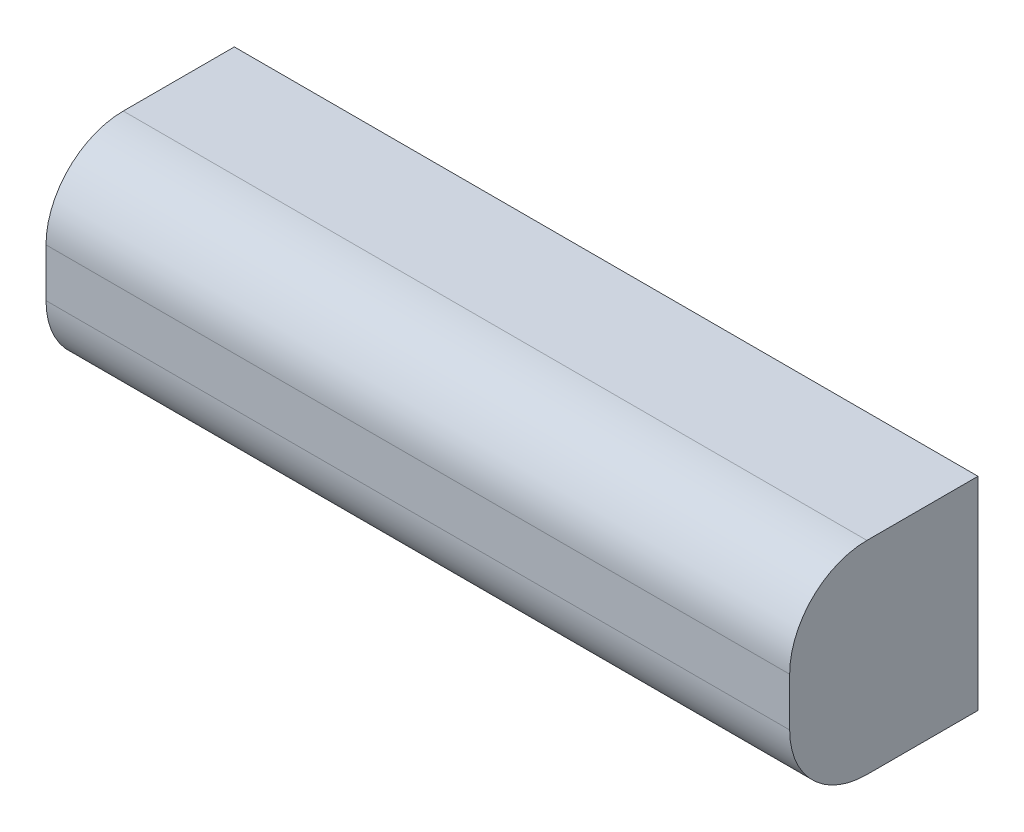
from build123d import *

# Parameters (mm, degrees)
SKICA1_W                = 77
SKICA1_H                = 21
P_IDAT_VYSUNUT_M1_DEPTH = 19.5
ZAOBLIT1_R              = 8


with BuildPart() as part:
    # Skica1 → Přidat vysunutím1 (new body)
    with BuildSketch(Plane.XY):
        Rectangle(SKICA1_W, SKICA1_H)
    extrude(amount=P_IDAT_VYSUNUT_M1_DEPTH)

    # Zaoblit1
    zaoblit1_edges = [part.edges().sort_by_distance(p)[0] for p in [
        (0, -10.5, 19.5),
        (0, 10.5, 19.5),
    ]]
    fillet(zaoblit1_edges, radius=ZAOBLIT1_R)


solid = part.part
